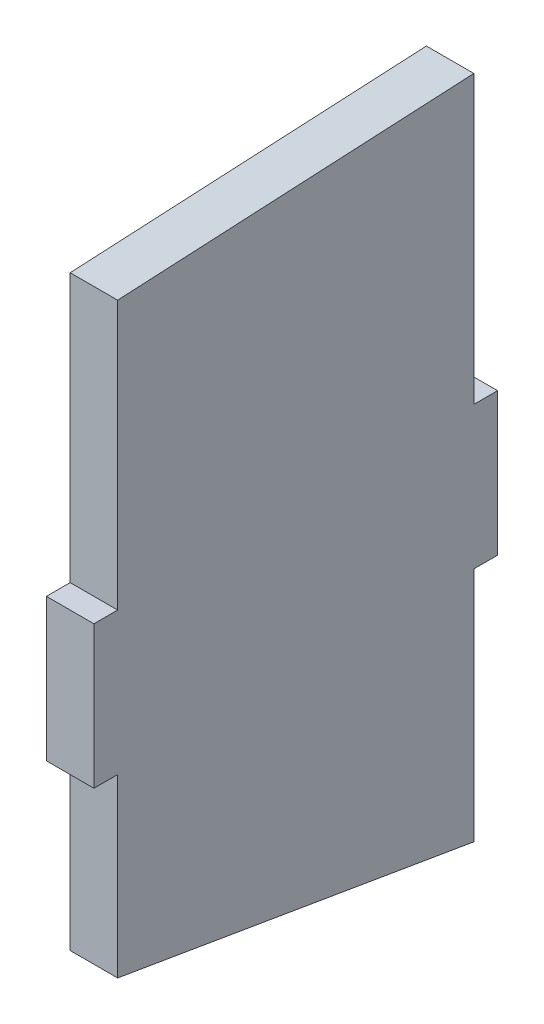
from build123d import *

# Parameters (mm, degrees)
SKETCH1_W           = 12.7
SKETCH1_H           = 76.2
SKETCH1_W_2         = 190.5
BOSS_EXTRUDE1_DEPTH = 25.4


with BuildPart() as part:
    # Sketch1 → Boss-Extrude1 (new body)
    with BuildSketch(Plane(origin=(0, 0, 0), x_dir=(0, 0, -1), z_dir=(1, 0, 0))):
        Polygon((95.25, 191.38745187), (-95.25, 181.62487678), (-95.25, 38.1), (95.25, 38.1), align=None)
        with Locations((101.6, 0)):
            Rectangle(SKETCH1_W, SKETCH1_H)
        Rectangle(SKETCH1_W_2, SKETCH1_H)
        with Locations((-101.6, 0)):
            Rectangle(SKETCH1_W, SKETCH1_H)
        Polygon((95.25, -38.1), (-95.25, -38.1), (-95.25, -132.320724436), (95.25, -164.508767502), align=None)
    extrude(amount=BOSS_EXTRUDE1_DEPTH)


solid = part.part
